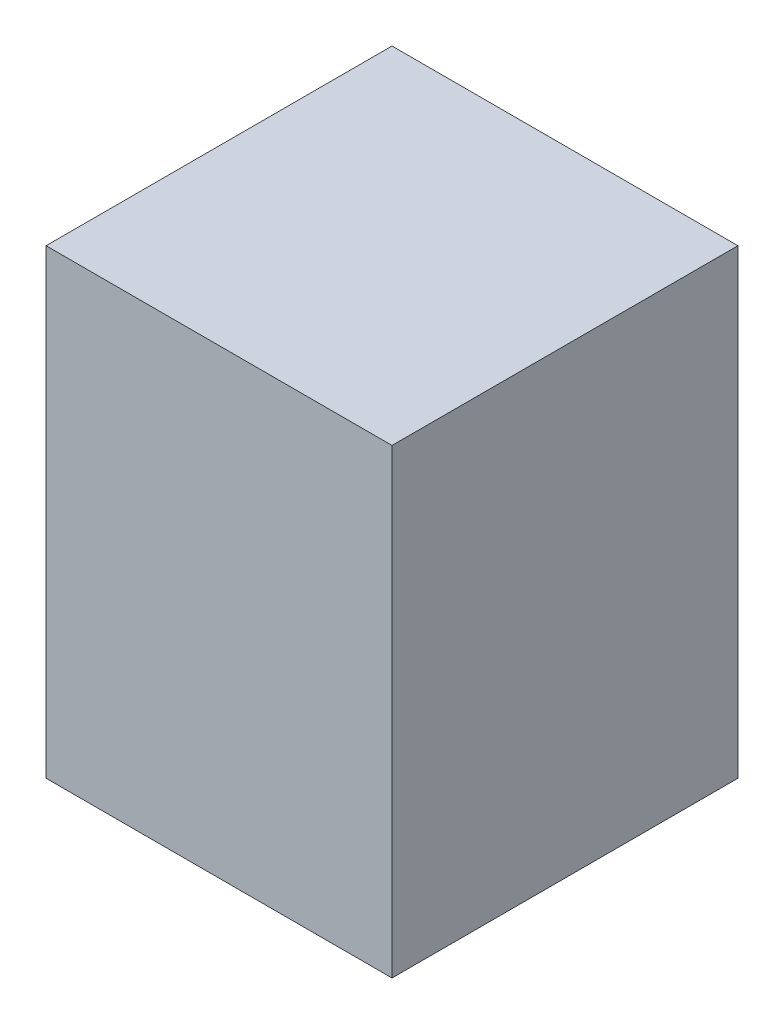
from build123d import *

# Parameters (mm, degrees)
CROQUIS1_W              = 30
CROQUIS1_H              = 30
SALIENTE_EXTRUIR1_DEPTH = 40


with BuildPart() as part:
    # Croquis1 → Saliente-Extruir1 (new body)
    with BuildSketch(Plane(origin=(0, 0, 0), x_dir=(1, 0, 0), z_dir=(0, 1, 0))):
        Rectangle(CROQUIS1_W, CROQUIS1_H)
    extrude(amount=SALIENTE_EXTRUIR1_DEPTH)


solid = part.part
